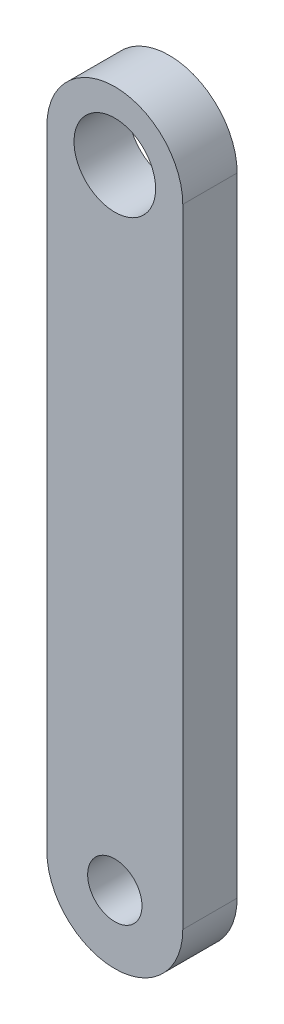
from build123d import *

# Parameters (mm, degrees)
SKETCH1_R           = 0.75
SKETCH1_R_2         = 0.5
BOSS_EXTRUDE1_DEPTH = 1


with BuildPart() as part:
    # Sketch1 → Boss-Extrude1 (new body)
    with BuildSketch(Plane.XY):
        with BuildLine():
            Line((-1.25, 5.7746852), (-1.25, -5.7746852))
            ThreePointArc((-1.25, -5.7746852), (0, -7.0246852), (1.25, -5.7746852))
            Line((1.25, -5.7746852), (1.25, 5.7746852))
            ThreePointArc((1.25, 5.7746852), (0, 7.0246852), (-1.25, 5.7746852))
        make_face()
        with Locations((0, 5.7746852)):
            Circle(SKETCH1_R, mode=Mode.SUBTRACT)
        with Locations((0, -5.7746852)):
            Circle(SKETCH1_R_2, mode=Mode.SUBTRACT)
    extrude(amount=BOSS_EXTRUDE1_DEPTH)


solid = part.part
